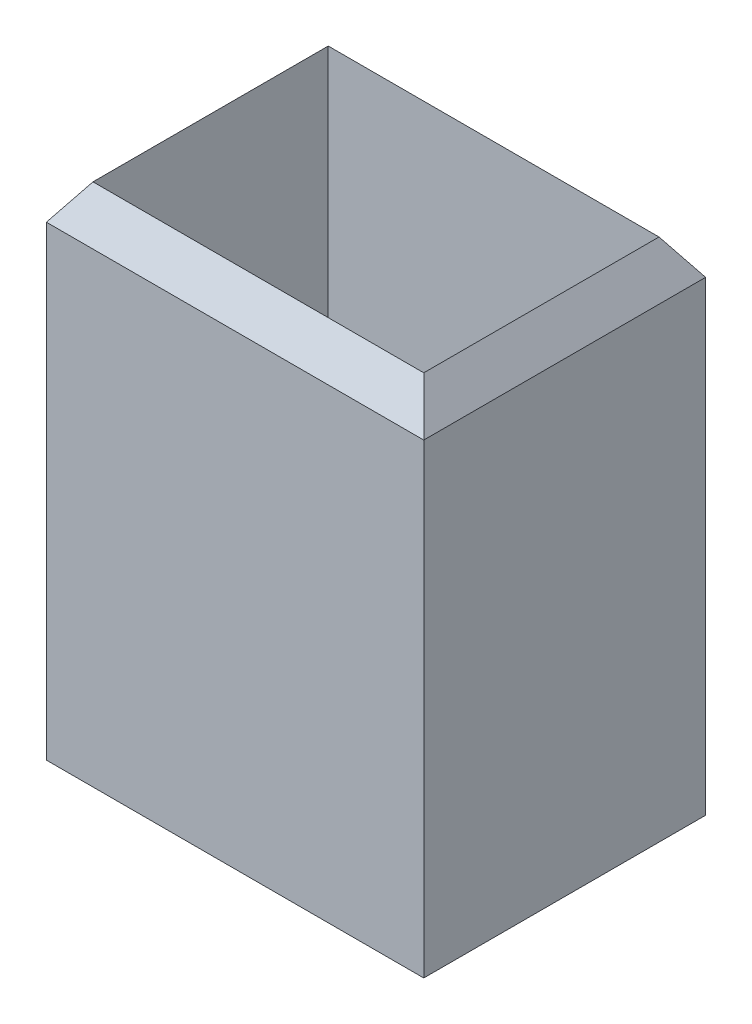
from build123d import *

# Parameters (mm, degrees)
SKETCH1_W           = 16.2
SKETCH1_H           = 12.1
BOSS_EXTRUDE1_DEPTH = 20
SKETCH2_2_W         = 14.2
SKETCH2_2_H         = 10.1
CUT_EXTRUDE1_DEPTH  = 24.75841962


with BuildPart() as part:
    # Sketch1 → Boss-Extrude1 (new body)
    with BuildSketch(Plane(origin=(0, 0, 0), x_dir=(1, 0, 0), z_dir=(0, 1, 0))):
        Rectangle(SKETCH1_W, SKETCH1_H)
    extrude(amount=BOSS_EXTRUDE1_DEPTH)

    # Sketch2 → section 1 of loft1
    with BuildSketch(Plane(origin=(0, 21.5, 0), x_dir=(1, 0, 0), z_dir=(0, 1, 0)), mode=Mode.PRIVATE) as loft1_s1:
        with BuildLine():
            Line((-7.1, -5.05), (7.1, -5.05))
            Line((7.1, -5.05), (7.1, 5.05))
            Line((7.1, 5.05), (-7.1, 5.05))
            Line((-7.1, 5.05), (-7.1, -5.05))
        make_face()
    # loft from a face of the part (loft1)
    loft([part.faces().sort_by_distance((0, 20, 0))[0], loft1_s1.sketch])

    # Sketch2_2 → Cut-Extrude1 (cut, through all)
    with BuildSketch(Plane(origin=(0, 21.5, 0), x_dir=(1, 0, 0), z_dir=(0, 1, 0))):
        Rectangle(SKETCH2_2_W, SKETCH2_2_H)
    extrude(amount=-CUT_EXTRUDE1_DEPTH, mode=Mode.SUBTRACT)


solid = part.part
